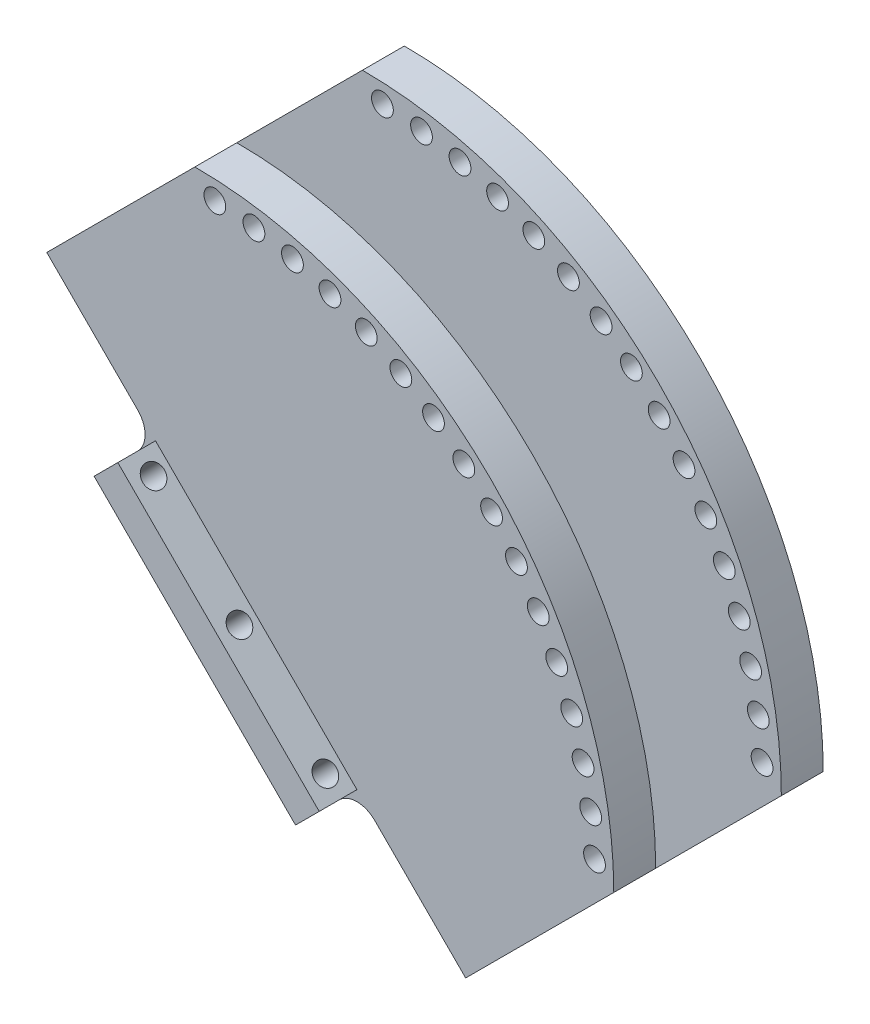
from build123d import *

# Parameters (mm, degrees)
SKETCH1_R           = 1.3
BOSS_EXTRUDE1_DEPTH = 5
SKETCH3_W           = 34
SKETCH3_H           = 17
SKETCH3_R           = 1.3
BOSS_EXTRUDE2_DEPTH = 4
FILLET1_R           = 3
FILLET2_R           = 3


with BuildPart() as part:
    # Sketch1 → Boss-Extrude1 (new body)
    with BuildSketch(Plane.XY):
        with BuildLine():
            Line((0, 50), (-17.67766953, 32.32233047))
            Line((-17.67766953, 32.32233047), (32.32233047, -17.67766953))
            Line((32.32233047, -17.67766953), (50, 0))
            ThreePointArc((50, 0), (35.355339059, 35.355339059), (0, 50))
        make_face()
        with Locations((47.7, 2.3)):
            Circle(SKETCH1_R, mode=Mode.SUBTRACT)
        with Locations((2.386492722, 47.695750885)):
            Circle(SKETCH1_R, mode=Mode.SUBTRACT)
        with Locations((7.050002215, 47.232165616)):
            Circle(SKETCH1_R, mode=Mode.SUBTRACT)
        with Locations((11.645616333, 46.313708772)):
            Circle(SKETCH1_R, mode=Mode.SUBTRACT)
        with Locations((16.129076799, 44.949225595)):
            Circle(SKETCH1_R, mode=Mode.SUBTRACT)
        with Locations((20.457205439, 43.151856804)):
            Circle(SKETCH1_R, mode=Mode.SUBTRACT)
        with Locations((24.588320007, 40.938912043)):
            Circle(SKETCH1_R, mode=Mode.SUBTRACT)
        with Locations((28.482635612, 38.331703179)):
            Circle(SKETCH1_R, mode=Mode.SUBTRACT)
        with Locations((32.102647866, 35.355339059)):
            Circle(SKETCH1_R, mode=Mode.SUBTRACT)
        with Locations((35.413494072, 32.038483697)):
            Circle(SKETCH1_R, mode=Mode.SUBTRACT)
        with Locations((38.383288971, 28.413080223)):
            Circle(SKETCH1_R, mode=Mode.SUBTRACT)
        with Locations((40.983431815, 24.514043255)):
            Circle(SKETCH1_R, mode=Mode.SUBTRACT)
        with Locations((43.188881806, 20.378922649)):
            Circle(SKETCH1_R, mode=Mode.SUBTRACT)
        with Locations((44.978399257, 16.047541877)):
            Circle(SKETCH1_R, mode=Mode.SUBTRACT)
        with Locations((46.334750135, 11.561614505)):
            Circle(SKETCH1_R, mode=Mode.SUBTRACT)
        with Locations((47.24487204, 6.964342465)):
            Circle(SKETCH1_R, mode=Mode.SUBTRACT)
    boss_extrude1 = extrude(amount=BOSS_EXTRUDE1_DEPTH)

    # Sketch3 → Boss-Extrude2 (add)
    with BuildSketch(Plane(origin=(7.32233047, 7.32233047, 0), x_dir=(-0.7071067811865535, 0.7071067811865417, 0), z_dir=(-0.7071067811865417, -0.7071067811865535, 0))):
        with Locations((0, -4)):
            Rectangle(SKETCH3_W, SKETCH3_H)
        with Locations(Location((0, 2, 0), (0, 0, 180))):
            Circle(SKETCH3_R, mode=Mode.SUBTRACT)
        with Locations(Location((14.5, 2, 0), (0, 0, 180))):
            Circle(SKETCH3_R, mode=Mode.SUBTRACT)
        with Locations((-14.5, 2)):
            Circle(SKETCH3_R, mode=Mode.SUBTRACT)
    boss_extrude2 = extrude(amount=BOSS_EXTRUDE2_DEPTH)

    # Mirror1: Boss-Extrude2 across plane
    add(boss_extrude2.mirror(Plane.XY.offset(12.5)))

    # Mirror2: Boss-Extrude1 across plane
    add(boss_extrude1.mirror(Plane.XY.offset(12.5)))

    # Fillet1
    fillet1_edges = [part.edges().sort_by_distance(p)[0] for p in [
        (19.343145751, -4.69848481, 22.5),
    ]]
    fillet(fillet1_edges, radius=FILLET1_R)

    # Fillet2
    fillet2_edges = [part.edges().sort_by_distance(p)[0] for p in [
        (-4.69848481, 19.343145751, 22.5),
        (-4.69848481, 19.343145751, 2.5),
        (19.343145751, -4.69848481, 2.5),
    ]]
    fillet(fillet2_edges, radius=FILLET2_R)


solid = part.part
